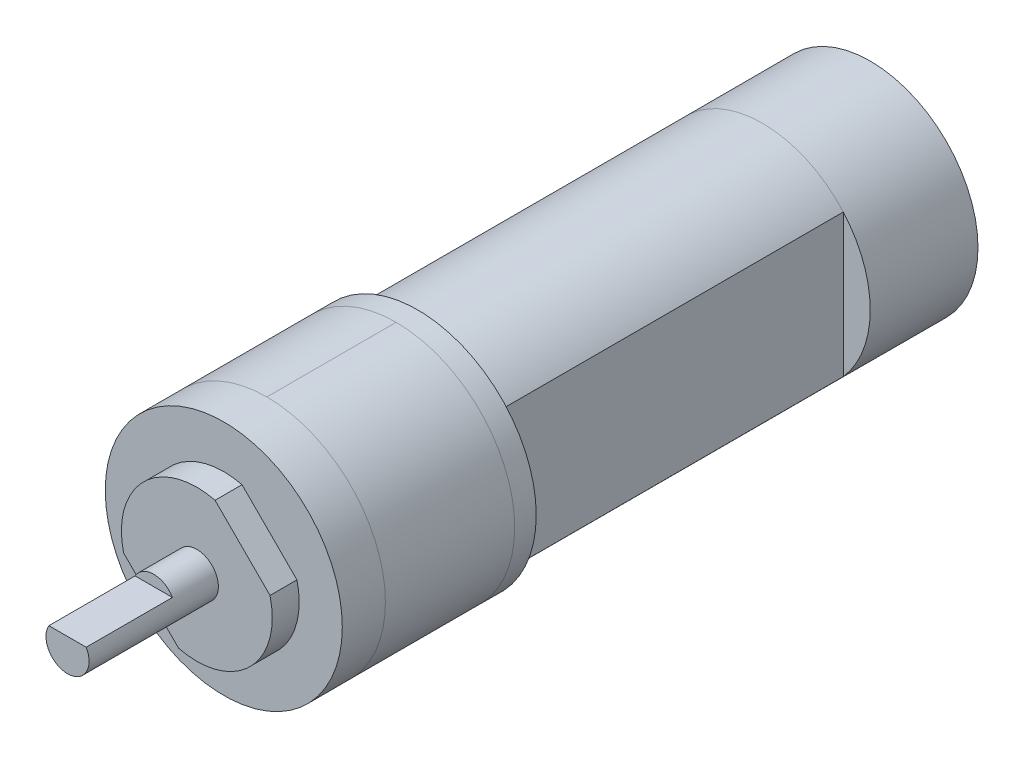
from build123d import *

# Parameters (mm, degrees)
SKETCH2_W           = 2.5
SKETCH2_H           = 7
SKETCH2_W_2         = 32
SKETCH2_H_2         = 10
SKETCH2_W_3         = 10
SKETCH4_W           = 3.5
SKETCH4_H           = 22
CUT_EXTRUDE1_DEPTH  = 32
CUT_EXTRUDE2_DEPTH  = 2.5
SKETCH6_R           = 2
BOSS_EXTRUDE1_DEPTH = 12
SKETCH7_W           = 4
SKETCH7_H           = 2
CUT_EXTRUDE3_DEPTH  = 8


with BuildPart() as part:
    # Sketch2 → Revolve1 (revolve)
    with BuildSketch(Plane(origin=(0, 0, 0), x_dir=(0, 0, -1), z_dir=(1, 0, 0)), mode=Mode.PRIVATE) as revolve1_sk:
        with Locations((-19.25, 3.5)):
            Rectangle(SKETCH2_W, SKETCH2_H)
        Polygon((-18, 0), (0, 0), (0, 10), (0, 11), (-18, 11), (-18, 7), align=None)
        with Locations((16, 5)):
            Rectangle(SKETCH2_W_2, SKETCH2_H_2)
        with Locations((37, 5)):
            Rectangle(SKETCH2_W_3, SKETCH2_H_2)
    revolve(revolve1_sk.sketch.rotate(Axis((0, 0, 51.295546559), (0, 0, -1)), 90), axis=Axis((0, 0, 51.295546559), (0, 0, -1)))

    # Sketch4 → Cut-Extrude1 (cut)
    with BuildSketch(Plane(origin=(0, 0, 0), x_dir=(-1, 0, 0), z_dir=(0, 0, -1))):
        with Locations((-9.25, 0)):
            Rectangle(SKETCH4_W, SKETCH4_H)
        with Locations((9.25, 0)):
            Rectangle(SKETCH4_W, SKETCH4_H)
    extrude(amount=CUT_EXTRUDE1_DEPTH, mode=Mode.SUBTRACT)

    # Sketch5 → Cut-Extrude2 (cut)
    with BuildSketch(Plane.XY.offset(20.5)):
        Polygon((-9.192388155, 0.707106781), (0.707106781, -9.192388155), (-2.828427125, -12.727922061), (-12.727922061, -2.828427125), align=None)
        Polygon((-0.707106781, 9.192388155), (9.192388155, -0.707106781), (12.727922061, 2.828427125), (2.828427125, 12.727922061), align=None)
    extrude(amount=-CUT_EXTRUDE2_DEPTH, mode=Mode.SUBTRACT)

    # Sketch6 → Boss-Extrude1 (add)
    with BuildSketch(Plane.XY.offset(20.5)):
        Circle(SKETCH6_R)
    extrude(amount=BOSS_EXTRUDE1_DEPTH)

    # Sketch7 → Cut-Extrude3 (cut)
    with BuildSketch(Plane.XY.offset(32.5)):
        with Locations((0, 2)):
            Rectangle(SKETCH7_W, SKETCH7_H)
    extrude(amount=-CUT_EXTRUDE3_DEPTH, mode=Mode.SUBTRACT)


solid = part.part
